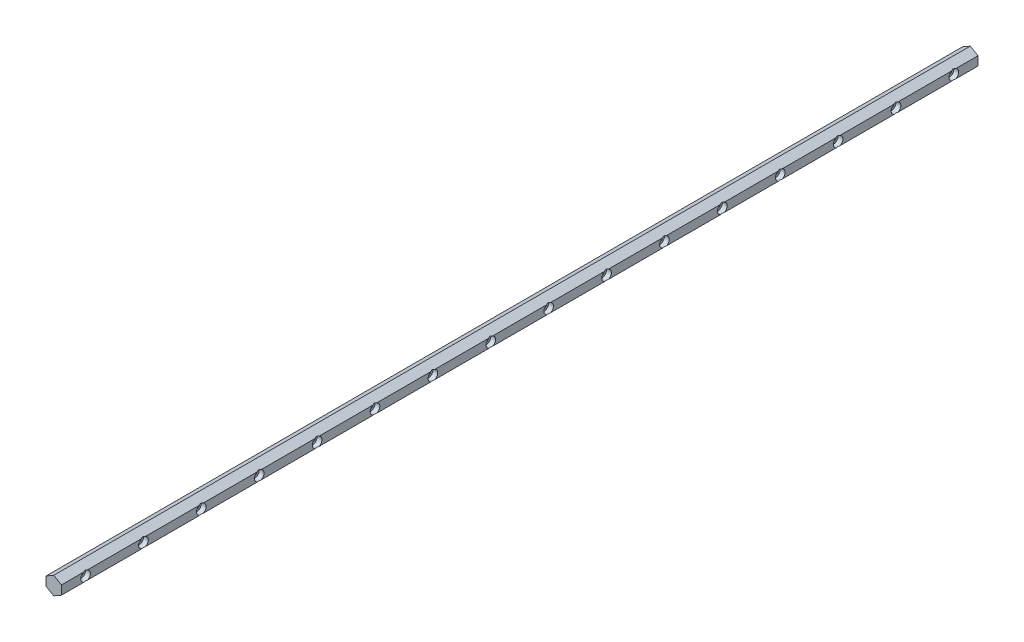
from build123d import *

# Parameters (mm, degrees)
BOSS_EXTRUDE1_DEPTH                             = 950
CBORE_FOR_M5_SOCKET_HEAD_CAP_SCREW2_D           = 5.5
CBORE_FOR_M5_SOCKET_HEAD_CAP_SCREW2_CBORE_D     = 10
CBORE_FOR_M5_SOCKET_HEAD_CAP_SCREW2_CBORE_DEPTH = 5
LPATTERN1_COUNT                                 = 16
LPATTERN1_PITCH                                 = 60


with BuildPart() as part:
    # Sketch1 → Boss-Extrude1 (new body)
    with BuildSketch(Plane.XY):
        Polygon((0, -9.237604307), (8, -4.618802154), (8, 4.618802154), (0, 9.237604307), (-8, 4.618802154), (-8, -4.618802154), align=None)
    extrude(amount=BOSS_EXTRUDE1_DEPTH)

    # CBORE for M5 Socket Head Cap Screw2 (through all)
    with Locations(Plane(origin=(8, 0, 925), x_dir=(0, 1, 0), z_dir=(1, 0, 0))):
        with Locations((0, 0)):
            cbore_for_m5_socket_head_cap_screw2 = CounterBoreHole(CBORE_FOR_M5_SOCKET_HEAD_CAP_SCREW2_D / 2, CBORE_FOR_M5_SOCKET_HEAD_CAP_SCREW2_CBORE_D / 2, CBORE_FOR_M5_SOCKET_HEAD_CAP_SCREW2_CBORE_DEPTH)

    # LPattern1: CBORE for M5 Socket Head Cap Screw2 ×16
    with Locations(*[(0, 0, -i * LPATTERN1_PITCH) for i in range(1, LPATTERN1_COUNT)]):
        add(cbore_for_m5_socket_head_cap_screw2, mode=Mode.SUBTRACT)


solid = part.part
